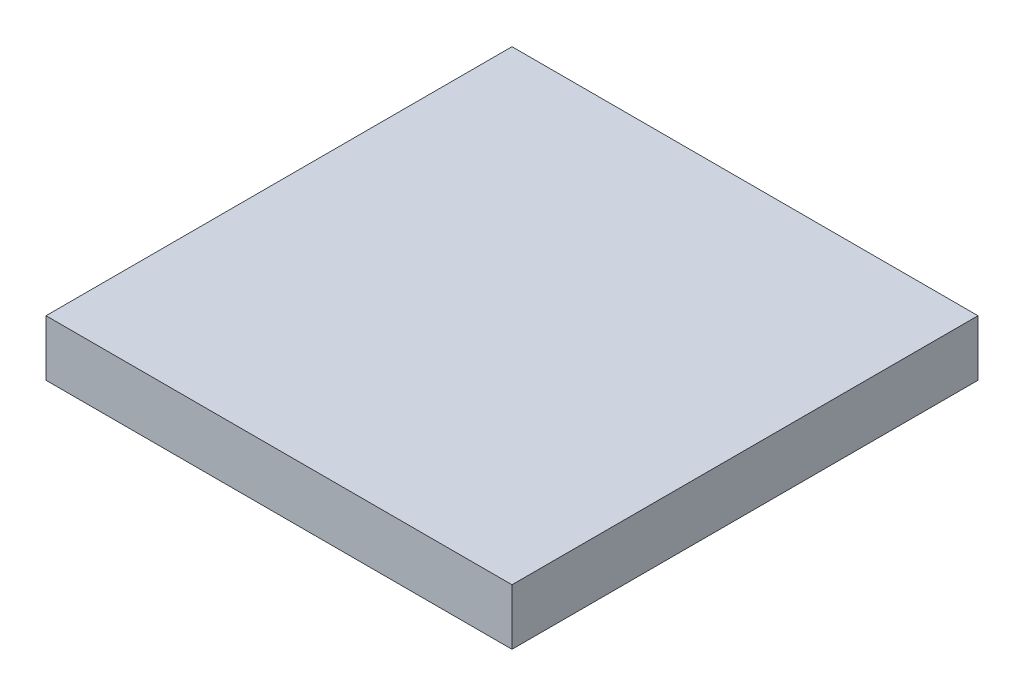
from build123d import *

# Parameters (mm, degrees)
SKETCH1_W           = 25
SKETCH1_H           = 25
BOSS_EXTRUDE1_DEPTH = 3
SKETCH2_R           = 10
SKETCH2_R_2         = 5
CUT_EXTRUDE1_DEPTH  = 2
SKETCH3_R           = 1.25
CUT_EXTRUDE2_DEPTH  = 2


with BuildPart() as part:
    # Sketch1 → Boss-Extrude1 (new body)
    with BuildSketch(Plane(origin=(0, 0, 0), x_dir=(1, 0, 0), z_dir=(0, 1, 0))):
        Rectangle(SKETCH1_W, SKETCH1_H)
    extrude(amount=BOSS_EXTRUDE1_DEPTH)

    # Sketch2 → Cut-Extrude1 (cut)
    with BuildSketch(Plane.XZ):
        Circle(SKETCH2_R)
        Circle(SKETCH2_R_2, mode=Mode.SUBTRACT)
    extrude(amount=-CUT_EXTRUDE1_DEPTH, mode=Mode.SUBTRACT)

    # Sketch3 → Cut-Extrude2 (cut)
    with BuildSketch(Plane.XZ):
        with Locations((-10.5, 10.5)):
            Circle(SKETCH3_R)
        with Locations((10.5, 10.5)):
            Circle(SKETCH3_R)
        with Locations((10.5, -10.5)):
            Circle(SKETCH3_R)
        with Locations((-10.5, -10.5)):
            Circle(SKETCH3_R)
    extrude(amount=-CUT_EXTRUDE2_DEPTH, mode=Mode.SUBTRACT)


solid = part.part
